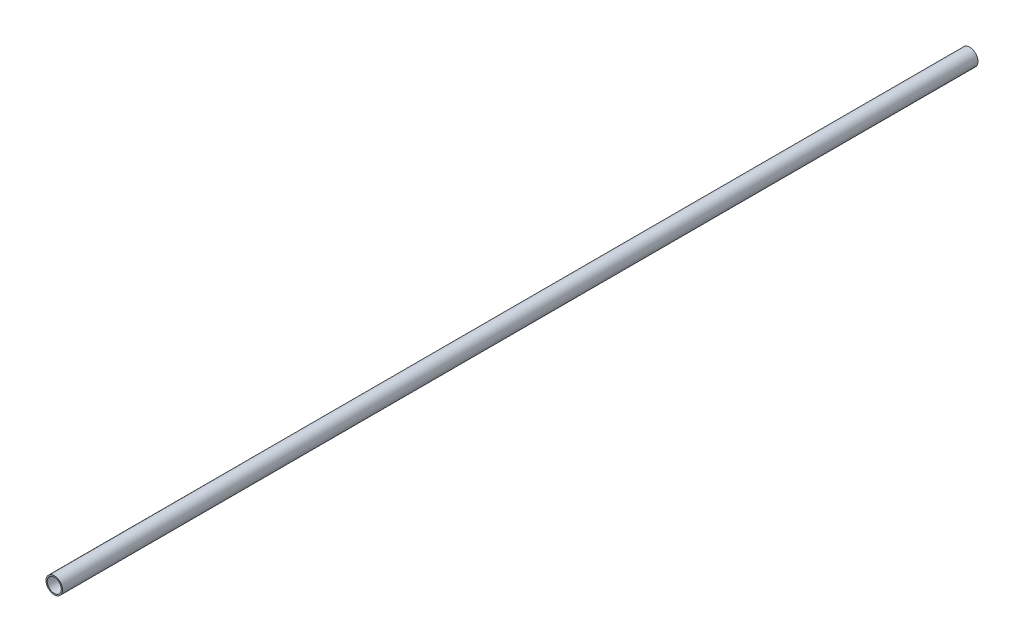
from build123d import *

# Parameters (mm, degrees)
SKETCH3_R           = 4.7625
SKETCH3_R_2         = 4.0513
BOSS_EXTRUDE1_DEPTH = 263.525


with BuildPart() as part:
    # Sketch3 → Boss-Extrude1 (new, symmetric)
    with BuildSketch(Plane.XY):
        Circle(SKETCH3_R)
        Circle(SKETCH3_R_2, mode=Mode.SUBTRACT)
    extrude(amount=BOSS_EXTRUDE1_DEPTH, both=True)


solid = part.part
